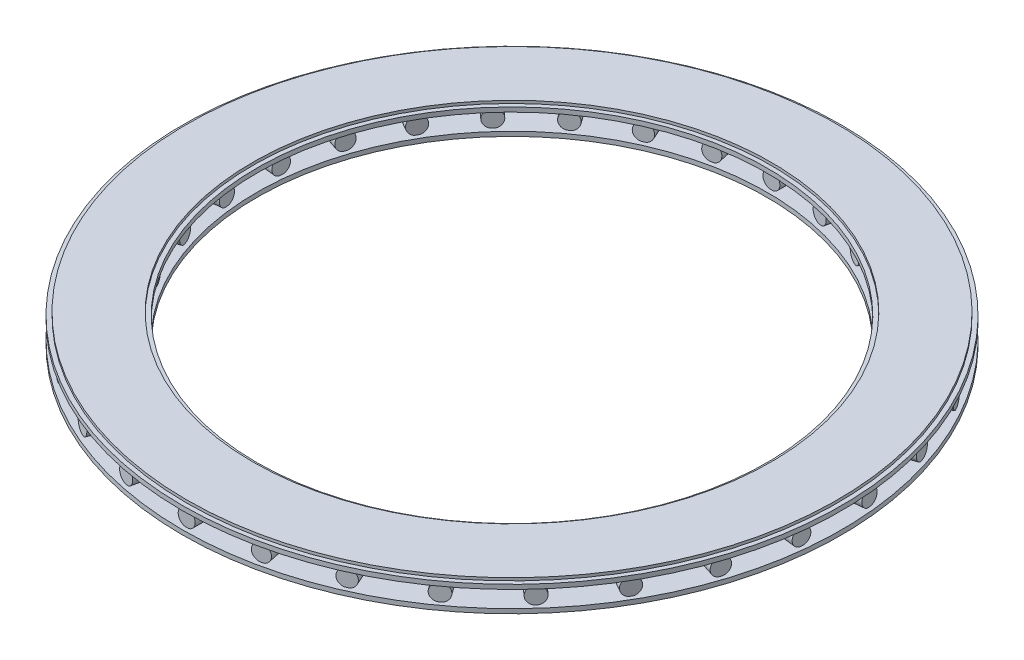
from build123d import *

# Parameters (mm, degrees)
SKETCH2_W           = 2
SKETCH2_H           = 15.5
CIRPATTERN2_COUNT   = 30
SKETCH4_R           = 77.5
SKETCH4_R_2         = 60
BOSS_EXTRUDE1_DEPTH = 1.05
SKETCH5_R           = 77.5
SKETCH5_R_2         = 60
BOSS_EXTRUDE2_DEPTH = 1.05
SKETCH6_R           = 76.5
SKETCH6_R_2         = 61
BOSS_EXTRUDE3_DEPTH = 0.65


with BuildPart() as part:
    # Sketch2 → Revolve1 (revolve)
    with BuildSketch(Plane(origin=(0, 0, 0), x_dir=(1, 0, 0), z_dir=(0, 1, 0))):
        with Locations((-1, -68.75)):
            Rectangle(SKETCH2_W, SKETCH2_H)
    revolve(axis=Axis((0, 0, 0), (0, 0, 1)))


with BuildPart() as cirpattern2_1:
    # CirPattern2: pattern copy
    add(part.part.rotate(Axis((0, 0, 0), (0, 1, 0)), 1 * 360 / CIRPATTERN2_COUNT))


with BuildPart() as cirpattern2_2:
    # CirPattern2: pattern copy
    add(part.part.rotate(Axis((0, 0, 0), (0, 1, 0)), 2 * 360 / CIRPATTERN2_COUNT))


with BuildPart() as cirpattern2_3:
    # CirPattern2: pattern copy
    add(part.part.rotate(Axis((0, 0, 0), (0, 1, 0)), 3 * 360 / CIRPATTERN2_COUNT))


with BuildPart() as cirpattern2_4:
    # CirPattern2: pattern copy
    add(part.part.rotate(Axis((0, 0, 0), (0, 1, 0)), 4 * 360 / CIRPATTERN2_COUNT))


with BuildPart() as cirpattern2_5:
    # CirPattern2: pattern copy
    add(part.part.rotate(Axis((0, 0, 0), (0, 1, 0)), 5 * 360 / CIRPATTERN2_COUNT))


with BuildPart() as cirpattern2_6:
    # CirPattern2: pattern copy
    add(part.part.rotate(Axis((0, 0, 0), (0, 1, 0)), 6 * 360 / CIRPATTERN2_COUNT))


with BuildPart() as cirpattern2_7:
    # CirPattern2: pattern copy
    add(part.part.rotate(Axis((0, 0, 0), (0, 1, 0)), 7 * 360 / CIRPATTERN2_COUNT))


with BuildPart() as cirpattern2_8:
    # CirPattern2: pattern copy
    add(part.part.rotate(Axis((0, 0, 0), (0, 1, 0)), 8 * 360 / CIRPATTERN2_COUNT))


with BuildPart() as cirpattern2_9:
    # CirPattern2: pattern copy
    add(part.part.rotate(Axis((0, 0, 0), (0, 1, 0)), 9 * 360 / CIRPATTERN2_COUNT))


with BuildPart() as cirpattern2_10:
    # CirPattern2: pattern copy
    add(part.part.rotate(Axis((0, 0, 0), (0, 1, 0)), 10 * 360 / CIRPATTERN2_COUNT))


with BuildPart() as cirpattern2_11:
    # CirPattern2: pattern copy
    add(part.part.rotate(Axis((0, 0, 0), (0, 1, 0)), 11 * 360 / CIRPATTERN2_COUNT))


with BuildPart() as cirpattern2_12:
    # CirPattern2: pattern copy
    add(part.part.rotate(Axis((0, 0, 0), (0, 1, 0)), 12 * 360 / CIRPATTERN2_COUNT))


with BuildPart() as cirpattern2_13:
    # CirPattern2: pattern copy
    add(part.part.rotate(Axis((0, 0, 0), (0, 1, 0)), 13 * 360 / CIRPATTERN2_COUNT))


with BuildPart() as cirpattern2_14:
    # CirPattern2: pattern copy
    add(part.part.rotate(Axis((0, 0, 0), (0, 1, 0)), 14 * 360 / CIRPATTERN2_COUNT))


with BuildPart() as cirpattern2_15:
    # CirPattern2: pattern copy
    add(part.part.rotate(Axis((0, 0, 0), (0, 1, 0)), 15 * 360 / CIRPATTERN2_COUNT))


with BuildPart() as cirpattern2_16:
    # CirPattern2: pattern copy
    add(part.part.rotate(Axis((0, 0, 0), (0, 1, 0)), 16 * 360 / CIRPATTERN2_COUNT))


with BuildPart() as cirpattern2_17:
    # CirPattern2: pattern copy
    add(part.part.rotate(Axis((0, 0, 0), (0, 1, 0)), 17 * 360 / CIRPATTERN2_COUNT))


with BuildPart() as cirpattern2_18:
    # CirPattern2: pattern copy
    add(part.part.rotate(Axis((0, 0, 0), (0, 1, 0)), 18 * 360 / CIRPATTERN2_COUNT))


with BuildPart() as cirpattern2_19:
    # CirPattern2: pattern copy
    add(part.part.rotate(Axis((0, 0, 0), (0, 1, 0)), 19 * 360 / CIRPATTERN2_COUNT))


with BuildPart() as cirpattern2_20:
    # CirPattern2: pattern copy
    add(part.part.rotate(Axis((0, 0, 0), (0, 1, 0)), 20 * 360 / CIRPATTERN2_COUNT))


with BuildPart() as cirpattern2_21:
    # CirPattern2: pattern copy
    add(part.part.rotate(Axis((0, 0, 0), (0, 1, 0)), 21 * 360 / CIRPATTERN2_COUNT))


with BuildPart() as cirpattern2_22:
    # CirPattern2: pattern copy
    add(part.part.rotate(Axis((0, 0, 0), (0, 1, 0)), 22 * 360 / CIRPATTERN2_COUNT))


with BuildPart() as cirpattern2_23:
    # CirPattern2: pattern copy
    add(part.part.rotate(Axis((0, 0, 0), (0, 1, 0)), 23 * 360 / CIRPATTERN2_COUNT))


with BuildPart() as cirpattern2_24:
    # CirPattern2: pattern copy
    add(part.part.rotate(Axis((0, 0, 0), (0, 1, 0)), 24 * 360 / CIRPATTERN2_COUNT))


with BuildPart() as cirpattern2_25:
    # CirPattern2: pattern copy
    add(part.part.rotate(Axis((0, 0, 0), (0, 1, 0)), 25 * 360 / CIRPATTERN2_COUNT))


with BuildPart() as cirpattern2_26:
    # CirPattern2: pattern copy
    add(part.part.rotate(Axis((0, 0, 0), (0, 1, 0)), 26 * 360 / CIRPATTERN2_COUNT))


with BuildPart() as cirpattern2_27:
    # CirPattern2: pattern copy
    add(part.part.rotate(Axis((0, 0, 0), (0, 1, 0)), 27 * 360 / CIRPATTERN2_COUNT))


with BuildPart() as cirpattern2_28:
    # CirPattern2: pattern copy
    add(part.part.rotate(Axis((0, 0, 0), (0, 1, 0)), 28 * 360 / CIRPATTERN2_COUNT))


with BuildPart() as cirpattern2_29:
    # CirPattern2: pattern copy
    add(part.part.rotate(Axis((0, 0, 0), (0, 1, 0)), 29 * 360 / CIRPATTERN2_COUNT))


with BuildPart() as part_1:
    add(part.part)

    add(cirpattern2_1.part)  # Boss-Extrude1 merges CirPattern2_1

    add(cirpattern2_2.part)  # Boss-Extrude1 merges CirPattern2_2

    add(cirpattern2_3.part)  # Boss-Extrude1 merges CirPattern2_3

    add(cirpattern2_4.part)  # Boss-Extrude1 merges CirPattern2_4

    add(cirpattern2_5.part)  # Boss-Extrude1 merges CirPattern2_5

    add(cirpattern2_6.part)  # Boss-Extrude1 merges CirPattern2_6

    add(cirpattern2_7.part)  # Boss-Extrude1 merges CirPattern2_7

    add(cirpattern2_8.part)  # Boss-Extrude1 merges CirPattern2_8

    add(cirpattern2_9.part)  # Boss-Extrude1 merges CirPattern2_9

    add(cirpattern2_10.part)  # Boss-Extrude1 merges CirPattern2_10

    add(cirpattern2_11.part)  # Boss-Extrude1 merges CirPattern2_11

    add(cirpattern2_12.part)  # Boss-Extrude1 merges CirPattern2_12

    add(cirpattern2_13.part)  # Boss-Extrude1 merges CirPattern2_13

    add(cirpattern2_14.part)  # Boss-Extrude1 merges CirPattern2_14

    add(cirpattern2_15.part)  # Boss-Extrude1 merges CirPattern2_15

    add(cirpattern2_16.part)  # Boss-Extrude1 merges CirPattern2_16

    add(cirpattern2_17.part)  # Boss-Extrude1 merges CirPattern2_17

    add(cirpattern2_18.part)  # Boss-Extrude1 merges CirPattern2_18

    add(cirpattern2_19.part)  # Boss-Extrude1 merges CirPattern2_19

    add(cirpattern2_20.part)  # Boss-Extrude1 merges CirPattern2_20

    add(cirpattern2_21.part)  # Boss-Extrude1 merges CirPattern2_21

    add(cirpattern2_22.part)  # Boss-Extrude1 merges CirPattern2_22

    add(cirpattern2_23.part)  # Boss-Extrude1 merges CirPattern2_23

    add(cirpattern2_24.part)  # Boss-Extrude1 merges CirPattern2_24

    add(cirpattern2_25.part)  # Boss-Extrude1 merges CirPattern2_25

    add(cirpattern2_26.part)  # Boss-Extrude1 merges CirPattern2_26

    add(cirpattern2_27.part)  # Boss-Extrude1 merges CirPattern2_27

    add(cirpattern2_28.part)  # Boss-Extrude1 merges CirPattern2_28

    add(cirpattern2_29.part)  # Boss-Extrude1 merges CirPattern2_29
    # Sketch4 → Boss-Extrude1 (add)
    with BuildSketch(Plane(origin=(0, 1.95, 0), x_dir=(1, 0, 0), z_dir=(0, 1, 0))):
        Circle(SKETCH4_R)
        Circle(SKETCH4_R_2, mode=Mode.SUBTRACT)
    extrude(amount=BOSS_EXTRUDE1_DEPTH)

    # Sketch5 → Boss-Extrude2 (add)
    with BuildSketch(Plane(origin=(0, -1.95, 0), x_dir=(1, 0, 0), z_dir=(0, 1, 0))):
        Circle(SKETCH5_R)
        Circle(SKETCH5_R_2, mode=Mode.SUBTRACT)
    extrude(amount=-BOSS_EXTRUDE2_DEPTH)


with BuildPart() as body_2:
    # Sketch6 → Boss-Extrude3 (new body)
    with BuildSketch(Plane(origin=(0, 3, 0), x_dir=(1, 0, 0), z_dir=(0, 1, 0))):
        Circle(SKETCH6_R)
        Circle(SKETCH6_R_2, mode=Mode.SUBTRACT)
    extrude(amount=BOSS_EXTRUDE3_DEPTH)


solid = Compound([part_1.part, body_2.part])
